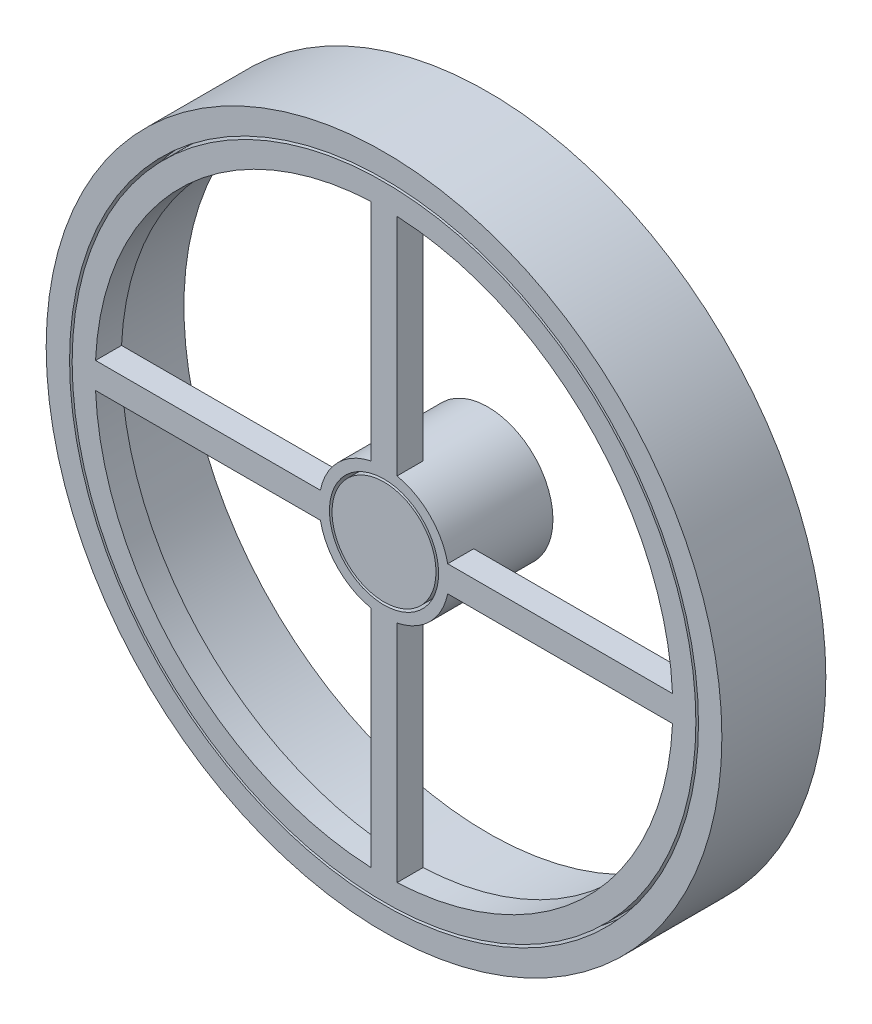
from build123d import *

# Parameters (mm, degrees)
SKETCH2_R           = 65
BOSS_EXTRUDE1_DEPTH = 20
SKETCH3_R           = 58.5
CUT_EXTRUDE1_DEPTH  = 20
SKETCH4_R           = 60.5
SKETCH4_R_2         = 60
CUT_EXTRUDE3_DEPTH  = 5
SKETCH5_R           = 10
BOSS_EXTRUDE2_DEPTH = 20
SKETCH6_R           = 58.5
SKETCH6_R_2         = 10.5
BOSS_EXTRUDE3_DEPTH = 5
CUT_EXTRUDE4_DEPTH  = 5
SKETCH9_R           = 12.5
SKETCH9_R_2         = 10
BOSS_EXTRUDE4_DEPTH = 15


with BuildPart() as part:
    # Sketch2 → Boss-Extrude1 (new body)
    with BuildSketch(Plane.XY):
        Circle(SKETCH2_R)
    extrude(amount=BOSS_EXTRUDE1_DEPTH)

    # Sketch3 → Cut-Extrude1 (cut)
    with BuildSketch(Plane.XY.offset(20)):
        Circle(SKETCH3_R)
    extrude(amount=-CUT_EXTRUDE1_DEPTH, mode=Mode.SUBTRACT)

    # Sketch4 → Cut-Extrude3 (cut)
    with BuildSketch(Plane.XY.offset(20)):
        Circle(SKETCH4_R)
        Circle(SKETCH4_R_2, mode=Mode.SUBTRACT)
    extrude(amount=-CUT_EXTRUDE3_DEPTH, mode=Mode.SUBTRACT)

    # Sketch6 → Boss-Extrude3 (add)
    with BuildSketch(Plane.XY.offset(20)):
        Circle(SKETCH6_R)
        Circle(SKETCH6_R_2, mode=Mode.SUBTRACT)
    extrude(amount=-BOSS_EXTRUDE3_DEPTH)

    # Sketch8 → Cut-Extrude4 (cut)
    with BuildSketch(Plane.XY.offset(20)):
        with BuildLine():
            Line((-2.5, 12.247448714), (-2.5, 55.5))
            ThreePointArc((-2.5, 55.5), (-39.284220751, 39.284220751), (-55.5, 2.5))
            Line((-55.5, 2.5), (-12.247448714, 2.5))
            ThreePointArc((-12.247448714, 2.5), (-8.838834765, 8.838834765), (-2.5, 12.247448714))
        make_face()
        with BuildLine():
            Line((2.5, -12.247448714), (2.5, -55.5))
            ThreePointArc((2.5, -55.5), (39.284220751, -39.284220751), (55.5, -2.5))
            Line((55.5, -2.5), (12.247448714, -2.5))
            ThreePointArc((12.247448714, -2.5), (8.838834765, -8.838834765), (2.5, -12.247448714))
        make_face()
        with BuildLine():
            Line((12.247448714, 2.5), (55.5, 2.5))
            ThreePointArc((55.5, 2.5), (39.284220751, 39.284220751), (2.5, 55.5))
            Line((2.5, 55.5), (2.5, 12.247448714))
            ThreePointArc((2.5, 12.247448714), (8.838834765, 8.838834765), (12.247448714, 2.5))
        make_face()
        with BuildLine():
            ThreePointArc((-12.247448714, -2.5), (-8.838834765, -8.838834765), (-2.5, -12.247448714))
            Line((-2.5, -12.247448714), (-2.5, -55.5))
            ThreePointArc((-2.5, -55.5), (-39.284220751, -39.284220751), (-55.5, -2.5))
            Line((-55.5, -2.5), (-12.247448714, -2.5))
        make_face()
    extrude(amount=-CUT_EXTRUDE4_DEPTH, mode=Mode.SUBTRACT)



with BuildPart() as body_2:
    # Sketch5 → Boss-Extrude2 (new body)
    with BuildSketch(Plane.XY.offset(20)):
        Circle(SKETCH5_R)
    extrude(amount=-BOSS_EXTRUDE2_DEPTH)


with BuildPart() as part_1:
    add(part.part)

    add(body_2.part)  # Boss-Extrude4 merges body 2
    # Sketch9 → Boss-Extrude4 (add)
    with BuildSketch(Plane(origin=(0, 0, 15), x_dir=(-1, 0, 0), z_dir=(0, 0, -1))):
        Circle(SKETCH9_R)
        Circle(SKETCH9_R_2, mode=Mode.SUBTRACT)
    extrude(amount=BOSS_EXTRUDE4_DEPTH)


solid = part_1.part
